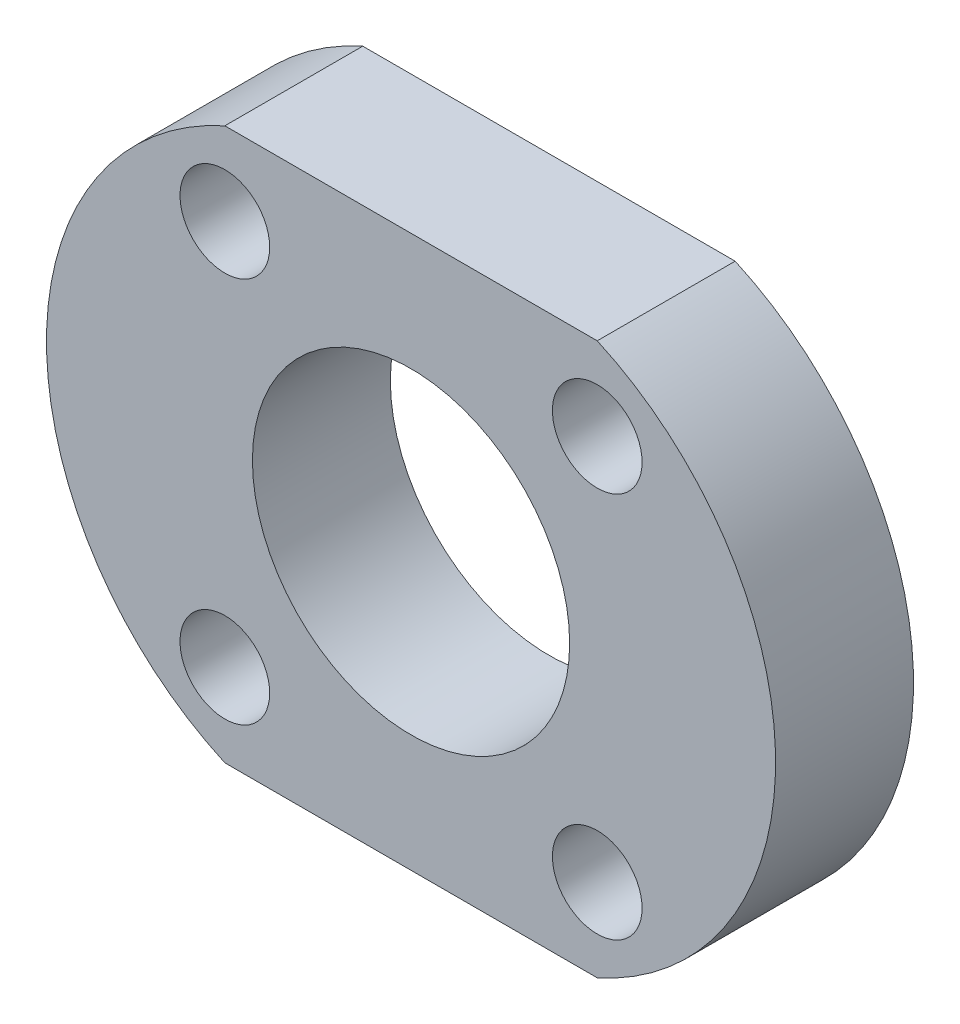
from build123d import *

# Parameters (mm, degrees)
BOSS_EXTRUDE1_DEPTH = 10
SKETCH3_R           = 11.5
CUT_EXTRUDE1_DEPTH  = 11
SKETCH4_R           = 3.25
CUT_EXTRUDE2_DEPTH  = 11


with BuildPart() as part:
    # Sketch2 → Boss-Extrude1 (new body)
    with BuildSketch(Plane.XY):
        with BuildLine():
            Line((-13.5, 20), (13.5, 20))
            ThreePointArc((13.5, 20), (26.431712199, 0), (13.5, -20))
            Line((13.5, -20), (-13.5, -20))
            ThreePointArc((-13.5, -20), (-26.431712199, 0), (-13.5, 20))
        make_face()
    extrude(amount=BOSS_EXTRUDE1_DEPTH)

    # Sketch3 → Cut-Extrude1 (cut, through all)
    with BuildSketch(Plane.XY.offset(10)):
        Circle(SKETCH3_R)
    extrude(amount=-CUT_EXTRUDE1_DEPTH, mode=Mode.SUBTRACT)

    # Sketch4 → Cut-Extrude2 (cut, through all)
    with BuildSketch(Plane.XY.offset(10)):
        with Locations((-13.5, 14)):
            Circle(SKETCH4_R)
        with Locations((-13.5, -14)):
            Circle(SKETCH4_R)
        with Locations((13.5, -14)):
            Circle(SKETCH4_R)
        with Locations((13.5, 14)):
            Circle(SKETCH4_R)
    extrude(amount=-CUT_EXTRUDE2_DEPTH, mode=Mode.SUBTRACT)


solid = part.part
